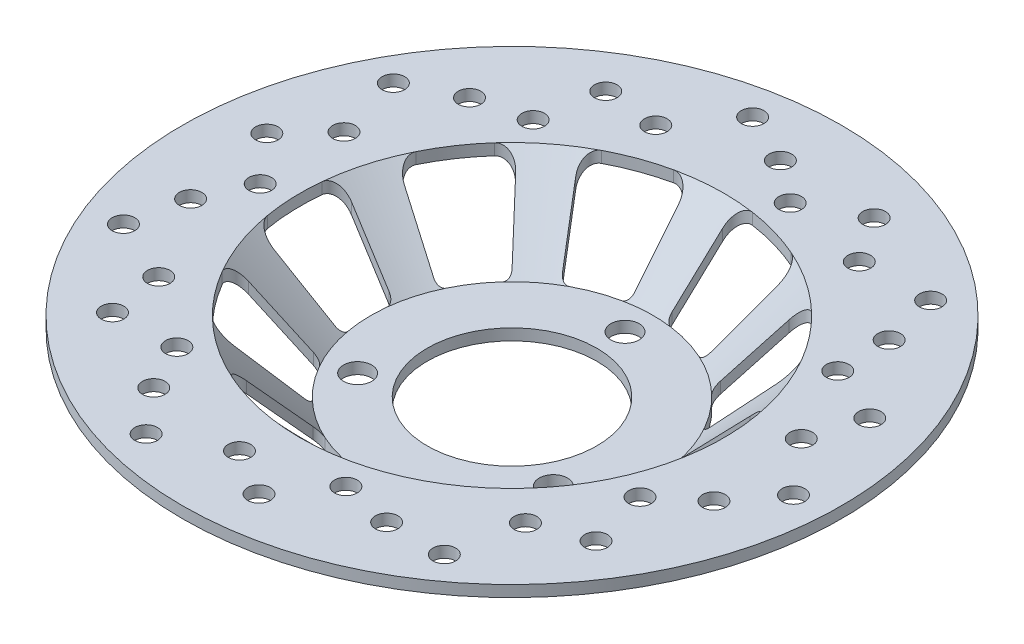
from build123d import *

# Parameters (mm, degrees)
SKETCH4_R          = 5
CUT_EXTRUDE1_DEPTH = 5
SKETCH5_R          = 4
CUT_EXTRUDE2_DEPTH = 4
CUT_EXTRUDE3_DEPTH = 29


with BuildPart() as part:
    # Sketch3 → Revolve3 (revolve)
    with BuildSketch(Plane.XY):
        Polygon((-30, 0), (-50, 0), (-75, 25), (-116.655, 25), (-116.655, 29), (-75, 29), (-50, 4), (-30, 4), align=None)
    revolve(axis=Axis((0, 0, 0), (0, 1, 0)))

    # Sketch4 → Cut-Extrude1 (cut, through all)
    with BuildSketch(Plane(origin=(0, 4, 0), x_dir=(1, 0, 0), z_dir=(0, 1, 0))):
        with Locations((0, 40)):
            Circle(SKETCH4_R)
        with Locations((34.641016151, -20)):
            Circle(SKETCH4_R)
        with Locations((-34.641016151, -20)):
            Circle(SKETCH4_R)
    extrude(amount=-CUT_EXTRUDE1_DEPTH, mode=Mode.SUBTRACT)

    # Sketch5 → Cut-Extrude2 (cut)
    with BuildSketch(Plane(origin=(0, 29, 0), x_dir=(1, 0, 0), z_dir=(0, 1, 0))):
        with Locations((0, 95)):
            Circle(SKETCH5_R)
        with Locations((-18.232209805, 103.4)):
            Circle(SKETCH5_R)
        with Locations((14.760331555, 83.71)):
            Circle(SKETCH5_R)
        with Locations((69.473778408, 78.723361133)):
            Circle(SKETCH5_R)
        with Locations((74.273990834, 59.231531177)):
            Circle(SKETCH5_R)
        with Locations((74.650029594, 40.652239412)):
            Circle(SKETCH5_R)
        with Locations((104.864594474, -5.233574331)):
            Circle(SKETCH5_R)
        with Locations((92.618151657, -21.139488726)):
            Circle(SKETCH5_R)
        with Locations((78.326732766, -33.017486608)):
            Circle(SKETCH5_R)
        with Locations((61.290232052, -85.249521578)):
            Circle(SKETCH5_R)
        with Locations((41.218955216, -85.592042451)):
            Circle(SKETCH5_R)
        with Locations((23.02180859, -81.824371778)):
            Circle(SKETCH5_R)
        with Locations((-28.436925197, -101.070840304)):
            Circle(SKETCH5_R)
        with Locations((-41.218955216, -85.592042451)):
            Circle(SKETCH5_R)
        with Locations((-49.619007013, -69.015836086)):
            Circle(SKETCH5_R)
        with Locations((-96.750497766, -40.783754811)):
            Circle(SKETCH5_R)
        with Locations((-92.618151657, -21.139488726)):
            Circle(SKETCH5_R)
        with Locations((-84.895698292, -4.236968155)):
            Circle(SKETCH5_R)
        with Locations((-92.208972166, 50.214329891)):
            Circle(SKETCH5_R)
        with Locations((-74.273990834, 59.231531177)):
            Circle(SKETCH5_R)
        with Locations((-56.244197201, 63.732423215)):
            Circle(SKETCH5_R)
        with Locations((34.202282914, 93.97)):
            Circle(SKETCH5_R)
        with Locations((44.998679981, 77.94)):
            Circle(SKETCH5_R)
        with Locations((94.793479005, 31.848915126)):
            Circle(SKETCH5_R)
        with Locations((88.992163809, 13.413410479)):
            Circle(SKETCH5_R)
        with Locations((84.00325197, -54.255052437)):
            Circle(SKETCH5_R)
        with Locations((65.972733179, -61.213750717)):
            Circle(SKETCH5_R)
        with Locations((9.956862848, -99.503858914)):
            Circle(SKETCH5_R)
        with Locations((-6.725511132, -89.74570909)):
            Circle(SKETCH5_R)
        with Locations((-71.587247082, -69.82423012)):
            Circle(SKETCH5_R)
        with Locations((-74.359308386, -50.697318039)):
            Circle(SKETCH5_R)
        with Locations((-99.224699845, 12.434468109)):
            Circle(SKETCH5_R)
        with Locations((-85.999029772, 26.527187532)):
            Circle(SKETCH5_R)
        with Locations((-52.14392981, 85.329758235)):
            Circle(SKETCH5_R)
        with Locations((-32.879727679, 83.776179835)):
            Circle(SKETCH5_R)
    extrude(amount=-CUT_EXTRUDE2_DEPTH, mode=Mode.SUBTRACT)

    # Sketch6 → Cut-Extrude3 (cut)
    with BuildSketch(Plane(origin=(0, 29, 0), x_dir=(1, 0, 0), z_dir=(0, 1, 0))):
        with BuildLine():
            Line((5.14516264, 69.435868155), (4.540244021, 52.113265363))
            ThreePointArc((4.540244021, 52.113265363), (5.127754693, 50.414121018), (6.703543894, 49.548587258))
            ThreePointArc((6.703543894, 49.548587258), (13.781867791, 48.063084797), (20.571823267, 45.571922139))
            ThreePointArc((20.571823267, 45.571922139), (22.366831312, 45.470895343), (23.76547794, 46.600518246))
            Line((23.76547794, 46.600518246), (32.432058783, 61.611476595))
            ThreePointArc((32.432058783, 61.611476595), (32.852734799, 65.670280789), (30.109212604, 68.69086778))
            ThreePointArc((30.109212604, 68.69086778), (20.672801686, 72.094627195), (10.866553688, 74.208611434))
            ThreePointArc((10.866553688, 74.208611434), (6.939247678, 73.10085365), (5.14516264, 69.435868155))
        make_face()
        with BuildLine():
            Line((-9.976230596, 68.907817468), (-8.164421842, 51.669608655))
            ThreePointArc((-8.164421842, 51.669608655), (-8.631975049, 49.933620667), (-10.143549124, 48.960273806))
            ThreePointArc((-10.143549124, 48.960273806), (-17.101007166, 46.984631039), (-23.70064793, 44.025893378))
            ThreePointArc((-23.70064793, 44.025893378), (-25.484236152, 43.799899246), (-26.958274257, 44.829205788))
            Line((-26.958274257, 44.829205788), (-36.650855267, 59.199048077))
            ThreePointArc((-36.650855267, 59.199048077), (-37.353634406, 63.218620353), (-34.82750079, 66.42322778))
            ThreePointArc((-34.82750079, 66.42322778), (-25.651510749, 70.476946559), (-16.016614364, 73.269830519))
            ThreePointArc((-16.016614364, 73.269830519), (-12.021601797, 72.438726197), (-9.976230596, 68.907817468))
        make_face()
        with BuildLine():
            Line((44.975903296, 53.150546636), (34.304543401, 39.491828833))
            ThreePointArc((34.304543401, 39.491828833), (33.781117531, 37.771862074), (34.547209795, 36.1454049))
            ThreePointArc((34.547209795, 36.1454049), (39.40053768, 30.783073766), (43.42945838, 24.776645148))
            ThreePointArc((43.42945838, 24.776645148), (44.822268332, 23.639833496), (46.617772907, 23.731613761))
            Line((46.617772907, 23.731613761), (62.452404032, 30.781645759))
            ThreePointArc((62.452404032, 30.781645759), (65.178443326, 33.818020171), (64.734343732, 37.874328265))
            ThreePointArc((64.734343732, 37.874328265), (59.100806521, 46.174610649), (52.409953998, 53.648827778))
            ThreePointArc((52.409953998, 53.648827778), (48.581573005, 55.06104546), (44.975903296, 53.150546636))
        make_face()
        with BuildLine():
            Line((67.627377568, 16.563522823), (50.96567317, 11.785855968))
            ThreePointArc((50.96567317, 11.785855968), (49.53124165, 10.702035636), (49.195015771, 8.935906408))
            ThreePointArc((49.195015771, 8.935906408), (49.969541351, 1.744974835), (49.698516505, -5.482468163))
            ThreePointArc((49.698516505, -5.482468163), (50.157122303, -7.220841258), (51.663663104, -8.201960573))
            Line((51.663663104, -8.201960573), (68.61805362, -11.805727526))
            ThreePointArc((68.61805362, -11.805727526), (72.608201836, -10.95157472), (74.633155794, -7.408917345))
            ThreePointArc((74.633155794, -7.408917345), (74.954312026, 2.617462253), (73.934533229, 12.597015368))
            ThreePointArc((73.934533229, 12.597015368), (71.667388672, 15.989789359), (67.627377568, 16.563522823))
        make_face()
        with BuildLine():
            Line((64.447492179, -26.350203735), (48.159648047, -20.421913291))
            ThreePointArc((48.159648047, -20.421913291), (46.362114964, -20.455604666), (45.051997799, -21.686804612))
            ThreePointArc((45.051997799, -21.686804612), (41.451878628, -27.959645174), (36.984430516, -33.647464977))
            ThreePointArc((36.984430516, -33.647464977), (36.333660332, -35.323400078), (36.975789978, -37.002664742))
            Line((36.975789978, -37.002664742), (48.573938967, -49.883714159))
            ThreePointArc((48.573938967, -49.883714159), (52.304095107, -51.538040298), (56.02463903, -49.86220835))
            ThreePointArc((56.02463903, -49.86220835), (62.177817942, -41.93946776), (67.21863371, -33.266428756))
            ThreePointArc((67.21863371, -33.266428756), (67.37869775, -29.189022803), (64.447492179, -26.350203735))
        make_face()
        with BuildLine():
            Line((36.650855267, -59.199048077), (26.958274257, -44.829205788))
            ThreePointArc((26.958274257, -44.829205788), (25.484236152, -43.799899246), (23.70064793, -44.025893378))
            ThreePointArc((23.70064793, -44.025893378), (17.101007166, -46.984631039), (10.143549124, -48.960273806))
            ThreePointArc((10.143549124, -48.960273806), (8.631975049, -49.933620667), (8.164421842, -51.669608655))
            Line((8.164421842, -51.669608655), (9.976230596, -68.907817468))
            ThreePointArc((9.976230596, -68.907817468), (12.021601797, -72.438726197), (16.016614364, -73.269830519))
            ThreePointArc((16.016614364, -73.269830519), (25.651510749, -70.476946559), (34.82750079, -66.42322778))
            ThreePointArc((34.82750079, -66.42322778), (37.353634406, -63.218620353), (36.650855267, -59.199048077))
        make_face()
        with BuildLine():
            Line((-5.14516264, -69.435868155), (-4.540244021, -52.113265363))
            ThreePointArc((-4.540244021, -52.113265363), (-5.127754693, -50.414121018), (-6.703543894, -49.548587258))
            ThreePointArc((-6.703543894, -49.548587258), (-13.781867791, -48.063084797), (-20.571823267, -45.571922139))
            ThreePointArc((-20.571823267, -45.571922139), (-22.366831312, -45.470895343), (-23.76547794, -46.600518246))
            Line((-23.76547794, -46.600518246), (-32.432058783, -61.611476595))
            ThreePointArc((-32.432058783, -61.611476595), (-32.852734799, -65.670280789), (-30.109212604, -68.69086778))
            ThreePointArc((-30.109212604, -68.69086778), (-20.672801686, -72.094627195), (-10.866553688, -74.208611434))
            ThreePointArc((-10.866553688, -74.208611434), (-6.939247678, -73.10085365), (-5.14516264, -69.435868155))
        make_face()
        with BuildLine():
            Line((-44.975903296, -53.150546636), (-34.304543401, -39.491828833))
            ThreePointArc((-34.304543401, -39.491828833), (-33.781117531, -37.771862074), (-34.547209795, -36.1454049))
            ThreePointArc((-34.547209795, -36.1454049), (-39.40053768, -30.783073766), (-43.42945838, -24.776645148))
            ThreePointArc((-43.42945838, -24.776645148), (-44.822268332, -23.639833496), (-46.617772907, -23.731613761))
            Line((-46.617772907, -23.731613761), (-62.452404032, -30.781645759))
            ThreePointArc((-62.452404032, -30.781645759), (-65.178443326, -33.818020171), (-64.734343732, -37.874328265))
            ThreePointArc((-64.734343732, -37.874328265), (-59.100806521, -46.174610649), (-52.409953998, -53.648827778))
            ThreePointArc((-52.409953998, -53.648827778), (-48.581573005, -55.06104546), (-44.975903296, -53.150546636))
        make_face()
        with BuildLine():
            Line((-67.627377568, -16.563522823), (-50.96567317, -11.785855968))
            ThreePointArc((-50.96567317, -11.785855968), (-49.53124165, -10.702035636), (-49.195015771, -8.935906408))
            ThreePointArc((-49.195015771, -8.935906408), (-49.969541351, -1.744974835), (-49.698516505, 5.482468163))
            ThreePointArc((-49.698516505, 5.482468163), (-50.157122303, 7.220841258), (-51.663663104, 8.201960573))
            Line((-51.663663104, 8.201960573), (-68.61805362, 11.805727526))
            ThreePointArc((-68.61805362, 11.805727526), (-72.608201836, 10.95157472), (-74.633155794, 7.408917345))
            ThreePointArc((-74.633155794, 7.408917345), (-74.954312026, -2.617462253), (-73.934533229, -12.597015368))
            ThreePointArc((-73.934533229, -12.597015368), (-71.667388672, -15.989789359), (-67.627377568, -16.563522823))
        make_face()
        with BuildLine():
            Line((-64.447492179, 26.350203735), (-48.159648047, 20.421913291))
            ThreePointArc((-48.159648047, 20.421913291), (-46.362114964, 20.455604666), (-45.051997799, 21.686804612))
            ThreePointArc((-45.051997799, 21.686804612), (-41.451878628, 27.959645174), (-36.984430516, 33.647464977))
            ThreePointArc((-36.984430516, 33.647464977), (-36.333660332, 35.323400078), (-36.975789978, 37.002664742))
            Line((-36.975789978, 37.002664742), (-48.573938967, 49.883714159))
            ThreePointArc((-48.573938967, 49.883714159), (-52.304095107, 51.538040298), (-56.02463903, 49.86220835))
            ThreePointArc((-56.02463903, 49.86220835), (-62.177817942, 41.93946776), (-67.21863371, 33.266428756))
            ThreePointArc((-67.21863371, 33.266428756), (-67.37869775, 29.189022803), (-64.447492179, 26.350203735))
        make_face()
    extrude(amount=-CUT_EXTRUDE3_DEPTH, mode=Mode.SUBTRACT)


solid = part.part
